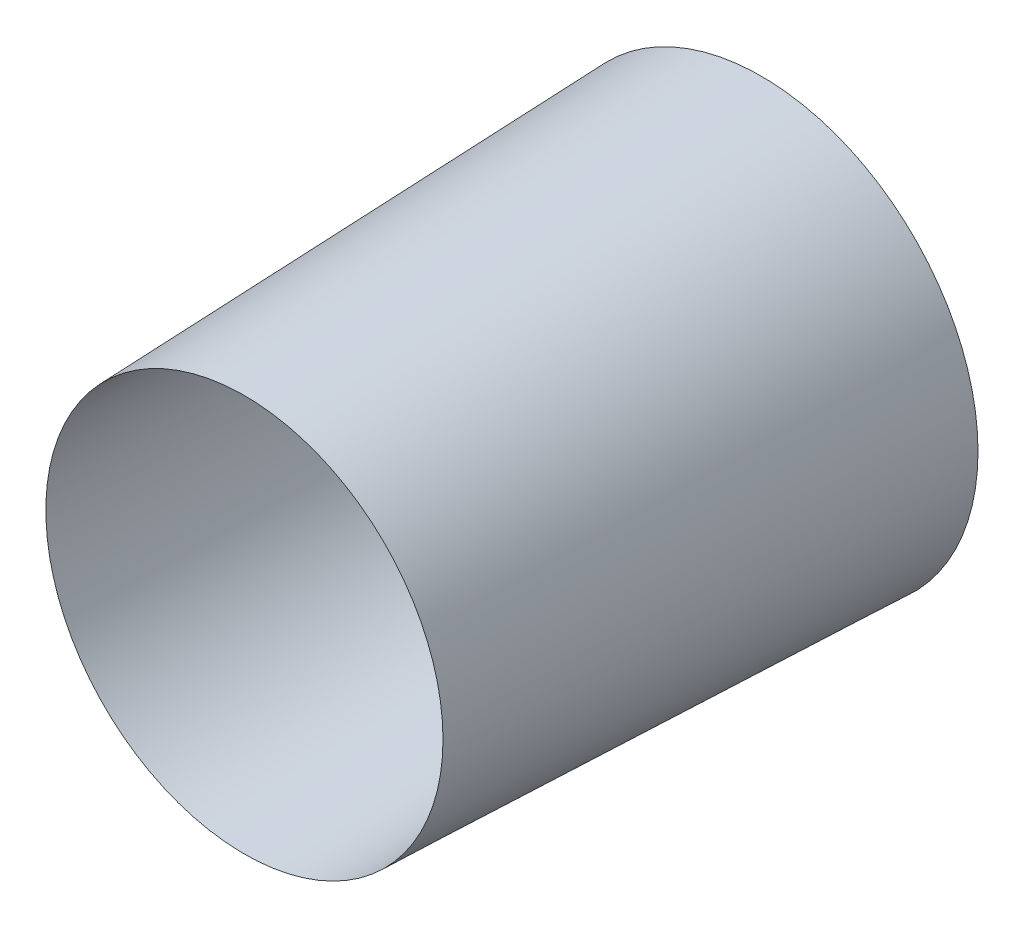
from build123d import *

# Parameters (mm, degrees)
SKETCH2_R           = 12
SKETCH2_R_2         = 10
EXTRUDE_THIN1_DEPTH = 30
EXTRUDE_THIN1_TAPER = 2


with BuildPart() as part:
    # Sketch2 → Extrude-Thin1 (new body)
    with BuildSketch(Plane.XY):
        Circle(SKETCH2_R)
        Circle(SKETCH2_R_2, mode=Mode.SUBTRACT)
    extrude(amount=EXTRUDE_THIN1_DEPTH, taper=EXTRUDE_THIN1_TAPER)


solid = part.part
